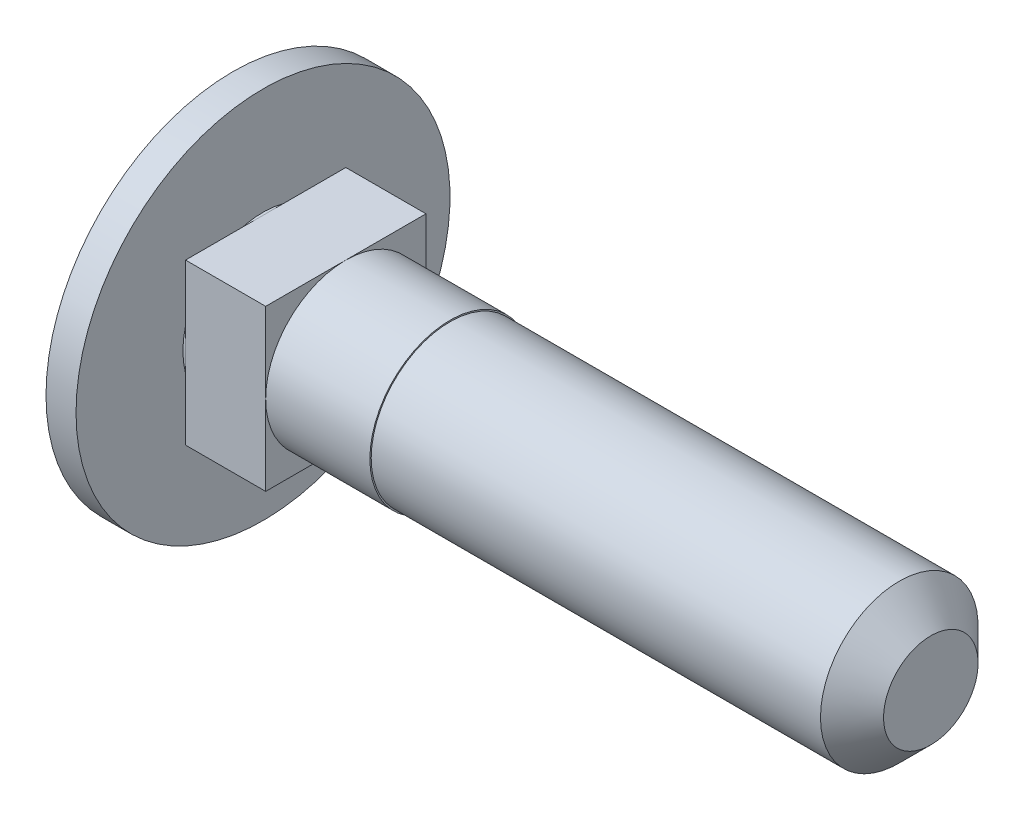
from build123d import *

# Parameters (mm, degrees)
EXTRUDE_START   = 0.1
SKETCH_2_W      = 6
SKETCH_2_H      = 6
EXTRUDE_1_DEPTH = 3
CHAMFER_1_SIZE  = 1.18


with BuildPart() as part:
    # Эскиз1 → Повернуть1 (revolve)
    with BuildSketch(Plane.XY, mode=Mode.PRIVATE) as revolve_1_sk:
        with BuildLine():
            Line((25, 0), (25, 2.95))
            Line((25, 2.95), (7, 2.95))
            Line((7, 2.95), (7, 3))
            Line((7, 3), (0, 3))
            Line((0, 3), (0, 7))
            Line((0, 7), (-1.124355653, 7))
            ThreePointArc((-1.124355653, 7), (-2.522961568, 3.623466631), (-3, 0))
            Line((-3, 0), (25, 0))
        make_face()
    revolve(revolve_1_sk.sketch.rotate(Axis((-121.430503085, 0, 0), (1, 0, 0)), 90), axis=Axis((-121.430503085, 0, 0), (1, 0, 0)))

    # Эскиз2 → Бобышка-Вытянуть1 (add)
    with BuildSketch(Plane(origin=(0, 0, 0), x_dir=(0, 0, -1), z_dir=(1, 0, 0)).offset(EXTRUDE_START)):
        Rectangle(SKETCH_2_W, SKETCH_2_H)
    extrude(amount=EXTRUDE_1_DEPTH)

    # Фаска1
    chamfer_1_edges = [part.edges().sort_by_distance(p)[0] for p in [
        (25, 0, -2.95),
    ]]
    chamfer(chamfer_1_edges, length=CHAMFER_1_SIZE)


solid = part.part
